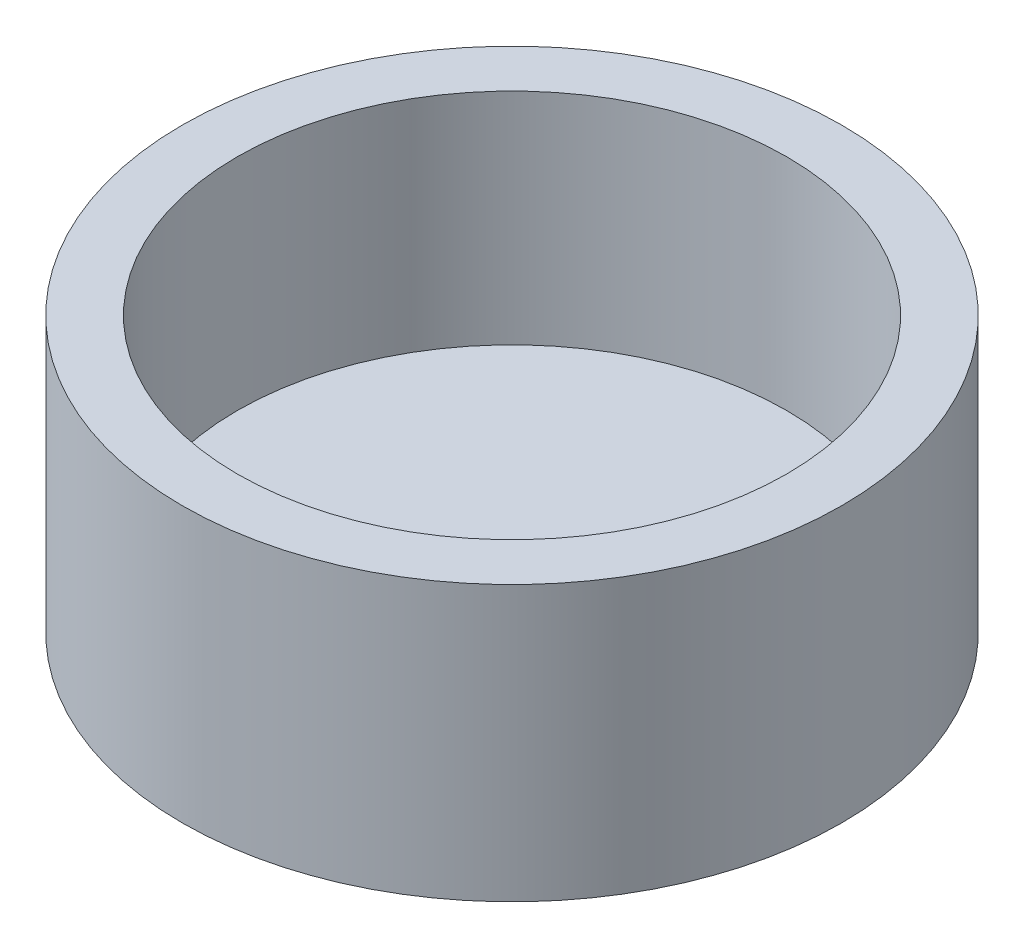
from build123d import *

# Parameters (mm, degrees)
SKETCH1_R           = 15
BOSS_EXTRUDE1_DEPTH = 12.5
SKETCH2_R           = 12.5
CUT_EXTRUDE1_DEPTH  = 10


with BuildPart() as part:
    # Sketch1 → Boss-Extrude1 (new body)
    with BuildSketch(Plane(origin=(0, 0, 0), x_dir=(1, 0, 0), z_dir=(0, 1, 0))):
        with Locations((-5.425115689, 4.310704304)):
            Circle(SKETCH1_R)
    extrude(amount=BOSS_EXTRUDE1_DEPTH)

    # Sketch2 → Cut-Extrude1 (cut)
    with BuildSketch(Plane(origin=(0, 12.5, 0), x_dir=(1, 0, 0), z_dir=(0, 1, 0))):
        with Locations((-5.425115689, 4.310704304)):
            Circle(SKETCH2_R)
    extrude(amount=-CUT_EXTRUDE1_DEPTH, mode=Mode.SUBTRACT)


solid = part.part
